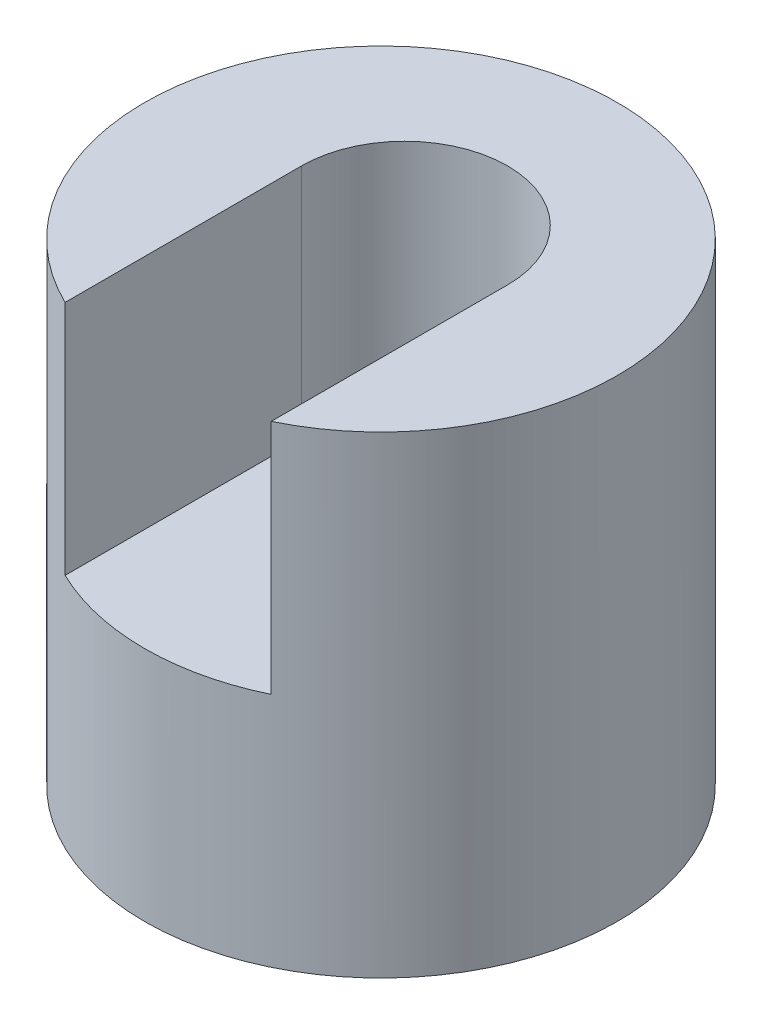
from build123d import *

# Parameters (mm, degrees)
SKETCH1_W           = 40
SKETCH1_H           = 40
BOSS_EXTRUDE1_DEPTH = 40
CUT_EXTRUDE1_DEPTH  = 40
SKETCH3_W           = 2
SKETCH3_H           = 20
CUT_EXTRUDE2_DEPTH  = 40
CUT_EXTRUDE3_DEPTH  = 20


with BuildPart() as part:
    # Sketch1 → Boss-Extrude1 (new body)
    with BuildSketch(Plane.XY):
        with Locations((20, 20)):
            Rectangle(SKETCH1_W, SKETCH1_H)
    extrude(amount=BOSS_EXTRUDE1_DEPTH)

    # Sketch2 → Cut-Extrude1 (cut)
    with BuildSketch(Plane(origin=(0, 40, 0), x_dir=(1, 0, 0), z_dir=(0, 1, 0))):
        with BuildLine():
            Line((20, 0), (0, 0))
            Line((0, 0), (0, -20))
            ThreePointArc((0, -20), (5.857864376, -5.857864376), (20, 0))
        make_face()
        with BuildLine():
            Line((40, 0), (20, 0))
            ThreePointArc((20, 0), (34.142135624, -5.857864376), (40, -20))
            Line((40, -20), (40, 0))
        make_face()
        with BuildLine():
            Line((40, -40), (40, -20))
            ThreePointArc((40, -20), (34.142135624, -34.142135624), (20, -40))
            Line((20, -40), (40, -40))
        make_face()
        with BuildLine():
            ThreePointArc((20, -40), (5.857864376, -34.142135624), (0, -20))
            Line((0, -20), (0, -40))
            Line((0, -40), (20, -40))
        make_face()
    extrude(amount=-CUT_EXTRUDE1_DEPTH, mode=Mode.SUBTRACT)

    # Sketch3 → Cut-Extrude2 (cut)
    with BuildSketch(Plane(origin=(0, 0, 0), x_dir=(0, 0, -1), z_dir=(1, 0, 0))):
        with Locations((-39, 30)):
            Rectangle(SKETCH3_W, SKETCH3_H)
    extrude(amount=CUT_EXTRUDE2_DEPTH, mode=Mode.SUBTRACT)

    # Sketch4 → Cut-Extrude3 (cut)
    with BuildSketch(Plane(origin=(0, 40, 0), x_dir=(1, 0, 0), z_dir=(0, 1, 0))):
        with BuildLine():
            Line((11.282202113, -38), (11.282202113, -18))
            ThreePointArc((11.282202113, -18), (20, -9.282202113), (28.717797887, -18))
            Line((28.717797887, -18), (28.717797887, -38))
            Line((28.717797887, -38), (11.282202113, -38))
        make_face()
    extrude(amount=-CUT_EXTRUDE3_DEPTH, mode=Mode.SUBTRACT)


solid = part.part
